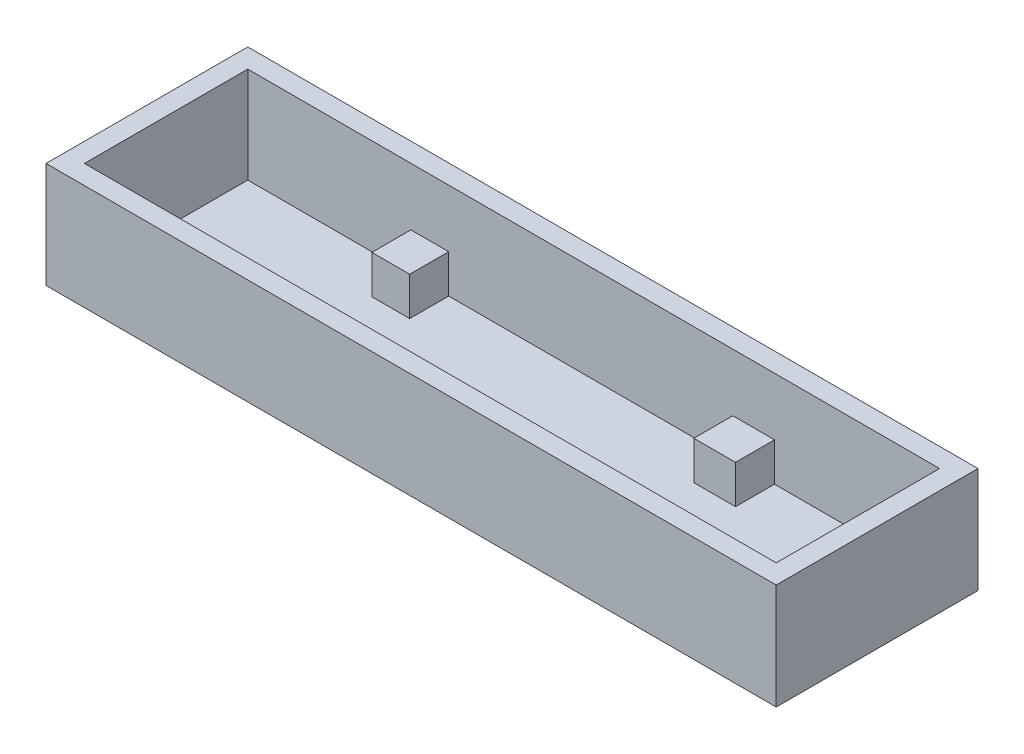
from build123d import *

# Parameters (mm, degrees)
SKETCH1_W           = 76
SKETCH1_H           = 21
SKETCH1_W_2         = 72
SKETCH1_H_2         = 17
BOSS_EXTRUDE1_DEPTH = 10
SKETCH2_W           = 76
SKETCH2_H           = 21
BOSS_EXTRUDE2_DEPTH = 1
SKETCH3_W           = 3.936198622
SKETCH3_H           = 4.059160528
SKETCH3_W_2         = 4.339911302
BOSS_EXTRUDE3_DEPTH = 4
SKETCH4_W           = 5
SKETCH4_H           = 5
BOSS_EXTRUDE4_DEPTH = 4


with BuildPart() as part:
    # Sketch1 → Boss-Extrude1 (new body)
    with BuildSketch(Plane(origin=(0, 0, 0), x_dir=(1, 0, 0), z_dir=(0, 1, 0))):
        with Locations((36, 8.5)):
            Rectangle(SKETCH1_W, SKETCH1_H)
        with Locations((36, 8.5)):
            Rectangle(SKETCH1_W_2, SKETCH1_H_2, mode=Mode.SUBTRACT)
    extrude(amount=BOSS_EXTRUDE1_DEPTH)

    # Sketch2 → Boss-Extrude2 (add)
    with BuildSketch(Plane.XZ):
        with Locations((36, -8.5)):
            Rectangle(SKETCH2_W, SKETCH2_H)
    extrude(amount=BOSS_EXTRUDE2_DEPTH)

    # Sketch3 → Boss-Extrude3 (add)
    with BuildSketch(Plane(origin=(0, 0, 0), x_dir=(1, 0, 0), z_dir=(0, 1, 0))):
        with Locations((18.943139302, 14.970419736)):
            Rectangle(SKETCH3_W, SKETCH3_H)
        with Locations((52.653148019, 14.970419736)):
            Rectangle(SKETCH3_W_2, SKETCH3_H)
    extrude(amount=BOSS_EXTRUDE3_DEPTH)

    # Sketch4 → Boss-Extrude4 (add)
    with BuildSketch(Plane(origin=(0, 0, 0), x_dir=(1, 0, 0), z_dir=(0, 1, 0))):
        with Locations((15.5, 2.5)):
            Rectangle(SKETCH4_W, SKETCH4_H)
        with Locations((61.5, 2.5)):
            Rectangle(SKETCH4_W, SKETCH4_H)
    extrude(amount=BOSS_EXTRUDE4_DEPTH)


solid = part.part
